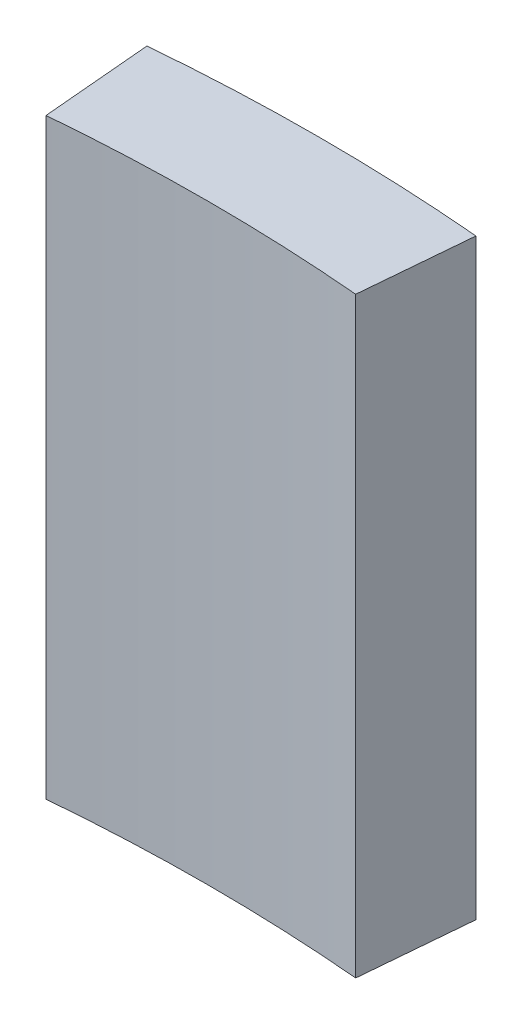
from build123d import *

# Parameters (mm, degrees)
SKETCH11_R                    = 161.925
SKETCH11_R_2                  = 152.4
PIPE_STANDARD_S40_P12_1_DEPTH = 50.8
CUT_EXTRUDE1_DEPTH            = 235.563533504


with BuildPart() as part:
    # Sketch11 → Pipe (standard, s40) P12(1) (new body)
    with BuildSketch(Plane(origin=(0, 0, 0), x_dir=(-1, 0, 0), z_dir=(0, 1, 0))):
        Circle(SKETCH11_R)
        Circle(SKETCH11_R_2, mode=Mode.SUBTRACT)
    extrude(amount=PIPE_STANDARD_S40_P12_1_DEPTH)

    # Sketch12 → Cut-Extrude1 (cut, through all)
    with BuildSketch(Plane(origin=(0, 50.8, 0), x_dir=(1, 0, 0), z_dir=(0, 1, 0))):
        with BuildLine():
            Line((0, 0), (-14.112693644, 161.308826489))
            ThreePointArc((-14.112693644, 161.308826489), (0, -161.925), (14.112693644, 161.308826489))
            Line((14.112693644, 161.308826489), (0, 0))
        make_face()
    extrude(amount=-CUT_EXTRUDE1_DEPTH, mode=Mode.SUBTRACT)


solid = part.part
